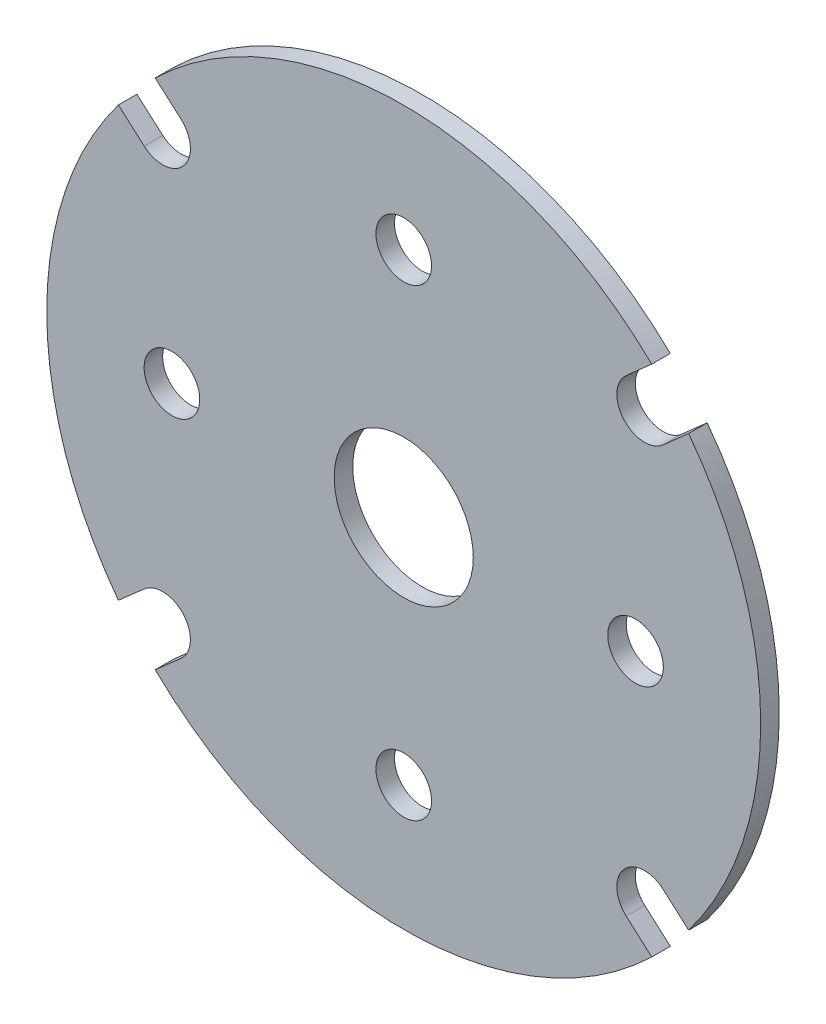
from build123d import *

# Parameters (mm, degrees)
MODEL_R             = 7.5
MODEL_R_2           = 3
BOSS_EXTRUDE1_DEPTH = 2


with BuildPart() as part:
    # Model → Boss-Extrude1 (new body)
    with BuildSketch(Plane.XY):
        with BuildLine():
            Line((30.727892071, -23.195832576), (27.969309055, -20.753740651))
            ThreePointArc((27.969309055, -20.753740651), (23.734502764, -21.011453059), (23.992215172, -25.246259349))
            Line((23.992215172, -25.246259349), (26.750798188, -27.688351274))
            ThreePointArc((26.750798188, -27.688351274), (-0.037885337, -38.49998136), (-26.805238954, -27.635650248))
            Line((-26.805238954, -27.635650248), (-24.022447477, -25.18187917))
            ThreePointArc((-24.022447477, -25.18187917), (-23.756401179, -20.947588277), (-27.990692072, -20.68154198))
            Line((-27.990692072, -20.68154198), (-30.773483549, -23.135313057))
            ThreePointArc((-30.773483549, -23.135313057), (-38.5, 0), (-30.773483549, 23.135313057))
            Line((-30.773483549, 23.135313057), (-27.990692072, 20.68154198))
            ThreePointArc((-27.990692072, 20.68154198), (-23.756401179, 20.947588277), (-24.022447477, 25.18187917))
            Line((-24.022447477, 25.18187917), (-26.805238954, 27.635650248))
            ThreePointArc((-26.805238954, 27.635650248), (-0.037885337, 38.49998136), (26.750798188, 27.688351274))
            Line((26.750798188, 27.688351274), (23.992215172, 25.246259349))
            ThreePointArc((23.992215172, 25.246259349), (23.734502764, 21.011453059), (27.969309055, 20.753740651))
            Line((27.969309055, 20.753740651), (30.727892071, 23.195832576))
            ThreePointArc((30.727892071, 23.195832576), (38.5, 0), (30.727892071, -23.195832576))
        make_face()
        Circle(MODEL_R, mode=Mode.SUBTRACT)
        with Locations((0, 25)):
            Circle(MODEL_R_2, mode=Mode.SUBTRACT)
        with Locations((25, 0)):
            Circle(MODEL_R_2, mode=Mode.SUBTRACT)
        with Locations((0, -25)):
            Circle(MODEL_R_2, mode=Mode.SUBTRACT)
        with Locations((-25, 0)):
            Circle(MODEL_R_2, mode=Mode.SUBTRACT)
    extrude(amount=BOSS_EXTRUDE1_DEPTH)


solid = part.part
